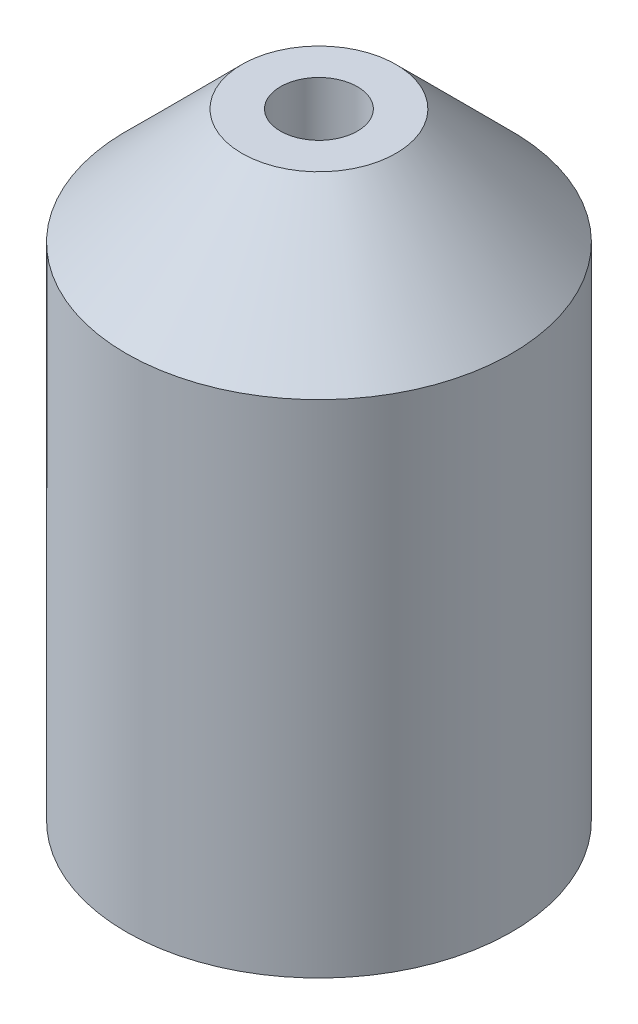
from build123d import *

# Parameters (mm, degrees)
SKETCH1_R           = 5
BOSS_EXTRUDE1_DEPTH = 16
CHAMFER1_SIZE       = 3
SKETCH2_R           = 1
CUT_EXTRUDE1_DEPTH  = 7
CUT_EXTRUDE2_DEPTH  = 7
CHAMFER2_SIZE       = 2.5


with BuildPart() as part:
    # Sketch1 → Boss-Extrude1 (new body)
    with BuildSketch(Plane(origin=(0, 0, 0), x_dir=(1, 0, 0), z_dir=(0, 1, 0))):
        Circle(SKETCH1_R)
    extrude(amount=BOSS_EXTRUDE1_DEPTH)

    # Chamfer1
    chamfer1_edges = [part.edges().sort_by_distance(p)[0] for p in [
        (-5, 16, 0),
    ]]
    chamfer(chamfer1_edges, length=CHAMFER1_SIZE)

    # Sketch2 → Cut-Extrude1 (cut)
    with BuildSketch(Plane(origin=(0, 16, 0), x_dir=(1, 0, 0), z_dir=(0, 1, 0))):
        Circle(SKETCH2_R)
    extrude(amount=-CUT_EXTRUDE1_DEPTH, mode=Mode.SUBTRACT)

    # Sketch3 → Cut-Extrude2 (cut)
    with BuildSketch(Plane.XZ):
        Polygon((-2.165063509, 3.75), (-4.330127019, 0), (-2.165063509, -3.75), (2.165063509, -3.75), (4.330127019, 0), (2.165063509, 3.75), align=None)
    extrude(amount=-CUT_EXTRUDE2_DEPTH, mode=Mode.SUBTRACT)

    # Chamfer2
    chamfer2_edges = [part.edges().sort_by_distance(p)[0] for p in [
        (0, 7, 3.75),
        (3.247595264, 7, 1.875),
        (3.247595264, 7, -1.875),
        (0, 7, -3.75),
        (-3.247595264, 7, -1.875),
        (-3.247595264, 7, 1.875),
    ]]
    chamfer(chamfer2_edges, length=CHAMFER2_SIZE)


solid = part.part
